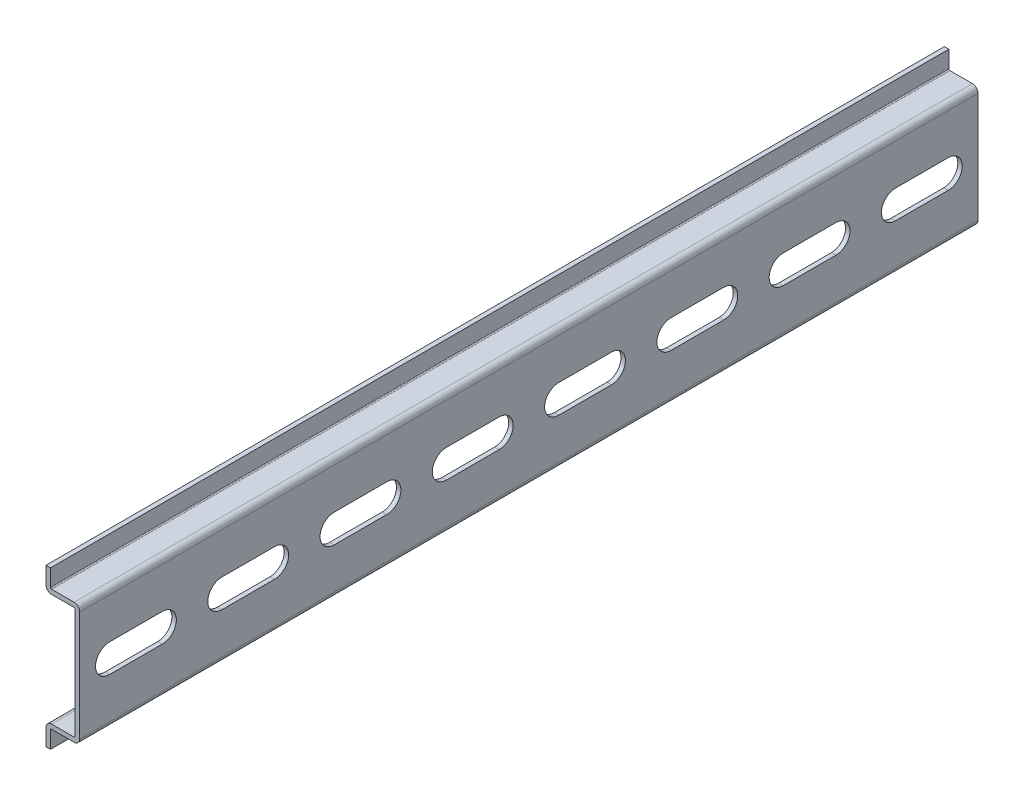
from build123d import *

# Parameters (mm, degrees)
EXTRUDE_THIN1_DEPTH = 200.025
CUT_EXTRUDE1_START  = -8.5
CUT_EXTRUDE1_DEPTH  = 9.5
LPATTERN1_COUNT     = 32
LPATTERN1_PITCH     = 25
FILLET1_R           = 0.25
FILLET2_R           = 1.25


with BuildPart() as part:
    # Sketch3 → Extrude-Thin1 (new body)
    with BuildSketch(Plane.XY):
        Polygon((-6.5, 17.5), (-6.5, 13.5), (0, 13.5), (0, -13.5), (-6.5, -13.5), (-6.5, -17.5), (-7.5, -17.5), (-7.5, -12.5), (-1, -12.5), (-1, 12.5), (-7.5, 12.5), (-7.5, 17.5), align=None)
    extrude(amount=EXTRUDE_THIN1_DEPTH)

    # Sketch4 → Cut-Extrude1 (cut)
    with BuildSketch(Plane(origin=(0, 0, 0), x_dir=(0, 0, -1), z_dir=(1, 0, 0)).offset(CUT_EXTRUDE1_START)):
        with BuildLine():
            Line((-6.65, -3.15), (-18.35, -3.15))
            ThreePointArc((-18.35, -3.15), (-21.5, 0), (-18.35, 3.15))
            Line((-18.35, 3.15), (-6.65, 3.15))
            ThreePointArc((-6.65, 3.15), (-3.5, 0), (-6.65, -3.15))
        make_face()
    cut_extrude1 = extrude(amount=CUT_EXTRUDE1_DEPTH, mode=Mode.SUBTRACT)

    # LPattern1: Cut-Extrude1 ×32
    with Locations(*[(0, 0, i * LPATTERN1_PITCH) for i in range(1, LPATTERN1_COUNT)]):
        add(cut_extrude1, mode=Mode.SUBTRACT)

    # Fillet1
    fillet1_edges = [part.edges().sort_by_distance(p)[0] for p in [
        (-6.5, 13.5, 100.0125),
        (-6.5, -13.5, 100.0125),
        (-1, -12.5, 100.0125),
        (-1, 12.5, 100.0125),
    ]]
    fillet(fillet1_edges, radius=FILLET1_R)

    # Fillet2
    fillet2_edges = [part.edges().sort_by_distance(p)[0] for p in [
        (0, 13.5, 100.0125),
        (0, -13.5, 100.0125),
        (-7.5, -12.5, 100.0125),
        (-7.5, 12.5, 100.0125),
    ]]
    fillet(fillet2_edges, radius=FILLET2_R)


solid = part.part
